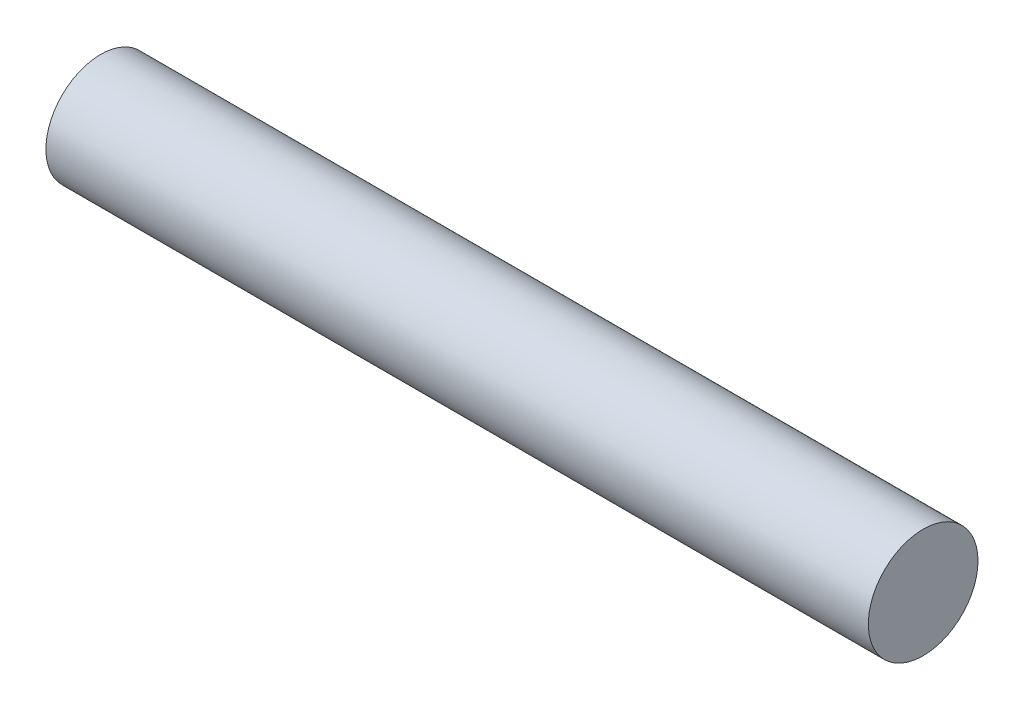
from build123d import *

# Parameters (mm, degrees)
SKETCH1_R           = 1.27
BOSS_EXTRUDE1_DEPTH = 19.05


with BuildPart() as part:
    # Sketch1 → Boss-Extrude1 (new body)
    with BuildSketch(Plane(origin=(0, 0, 0), x_dir=(0, 0, -1), z_dir=(1, 0, 0))):
        Circle(SKETCH1_R)
    extrude(amount=BOSS_EXTRUDE1_DEPTH)


solid = part.part
